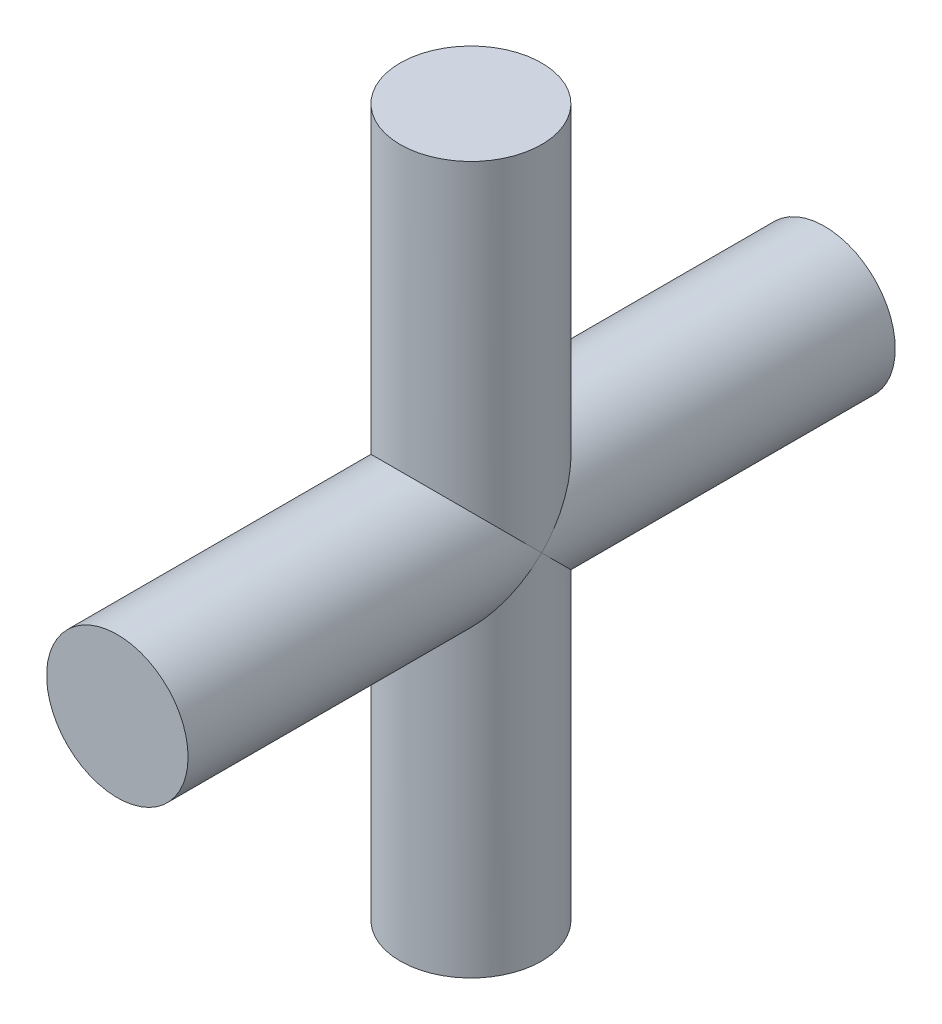
from build123d import *

# Parameters (mm, degrees)
SKETCH2_R           = 5
BOSS_EXTRUDE1_DEPTH = 50
SKETCH5_R           = 5
BOSS_EXTRUDE2_DEPTH = 50


with BuildPart() as part:
    # Sketch2 → Boss-Extrude1 (new body)
    with BuildSketch(Plane.XY):
        Circle(SKETCH2_R)
    extrude(amount=BOSS_EXTRUDE1_DEPTH)

    # Sketch5 → Boss-Extrude2 (add)
    with BuildSketch(Plane(origin=(0, 25, 0), x_dir=(1, 0, 0), z_dir=(0, 1, 0))):
        with Locations((0, -25)):
            Circle(SKETCH5_R)
    extrude(amount=-BOSS_EXTRUDE2_DEPTH)


solid = part.part
